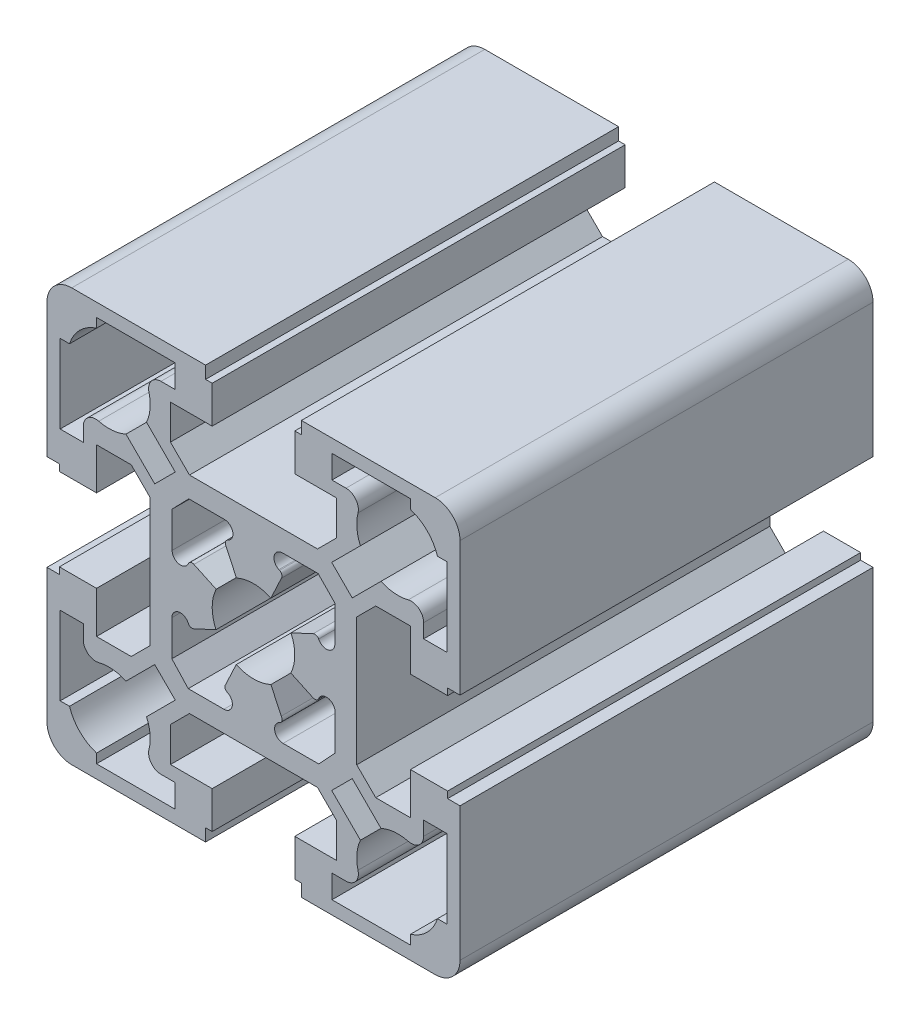
from build123d import *

# Parameters (mm, degrees)
BASE_EXTRUDE_DEPTH = 50


with BuildPart() as part:
    # Sketch1 → Base-Extrude (new body)
    with BuildSketch(Plane.XY):
        with BuildLine():
            Line((7.75, 12.5), (-7.75, 12.5))
            Line((-7.75, 12.5), (-10.05, 14.8))
            Line((-10.05, 14.8), (-10.05, 19))
            Line((-10.05, 19), (-5, 19))
            Line((-5, 19), (-5, 23.5))
            Line((-5, 23.5), (-5.8, 23.5))
            Line((-5.8, 23.5), (-5.8, 25))
            Line((-5.8, 25), (-22, 25))
            ThreePointArc((-22, 25), (-24.121320344, 24.121320344), (-25, 22))
            Line((-25, 22), (-25, 5.8))
            Line((-25, 5.8), (-23.5, 5.8))
            Line((-23.5, 5.8), (-23.5, 5))
            Line((-23.5, 5), (-19, 5))
            Line((-19, 5), (-19, 10.05))
            Line((-19, 10.05), (-14.8, 10.05))
            Line((-14.8, 10.05), (-12.5, 7.75))
            Line((-12.5, 7.75), (-12.5, -7.75))
            Line((-12.5, -7.75), (-14.8, -10.05))
            Line((-14.8, -10.05), (-19, -10.05))
            Line((-19, -10.05), (-19, -5))
            Line((-19, -5), (-23.5, -5))
            Line((-23.5, -5), (-23.5, -5.8))
            Line((-23.5, -5.8), (-25, -5.8))
            Line((-25, -5.8), (-25, -22))
            ThreePointArc((-25, -22), (-24.121320344, -24.121320344), (-22, -25))
            Line((-22, -25), (-5.8, -25))
            Line((-5.8, -25), (-5.8, -23.5))
            Line((-5.8, -23.5), (-5, -23.5))
            Line((-5, -23.5), (-5, -19))
            Line((-5, -19), (-10.05, -19))
            Line((-10.05, -19), (-10.05, -14.8))
            Line((-10.05, -14.8), (-7.75, -12.5))
            Line((-7.75, -12.5), (7.75, -12.5))
            Line((7.75, -12.5), (10.05, -14.8))
            Line((10.05, -14.8), (10.05, -19))
            Line((10.05, -19), (5, -19))
            Line((5, -19), (5, -23.5))
            Line((5, -23.5), (5.8, -23.5))
            Line((5.8, -23.5), (5.8, -25))
            Line((5.8, -25), (22, -25))
            ThreePointArc((22, -25), (24.121320344, -24.121320344), (25, -22))
            Line((25, -22), (25, -5.8))
            Line((25, -5.8), (23.5, -5.8))
            Line((23.5, -5.8), (23.5, -5))
            Line((23.5, -5), (19, -5))
            Line((19, -5), (19, -10.05))
            Line((19, -10.05), (14.8, -10.05))
            Line((14.8, -10.05), (12.5, -7.75))
            Line((12.5, -7.75), (12.5, 7.75))
            Line((12.5, 7.75), (14.8, 10.05))
            Line((14.8, 10.05), (19, 10.05))
            Line((19, 10.05), (19, 5))
            Line((19, 5), (23.5, 5))
            Line((23.5, 5), (23.5, 5.8))
            Line((23.5, 5.8), (25, 5.8))
            Line((25, 5.8), (25, 22))
            ThreePointArc((25, 22), (24.121320344, 24.121320344), (22, 25))
            Line((22, 25), (5.8, 25))
            Line((5.8, 25), (5.8, 23.5))
            Line((5.8, 23.5), (5, 23.5))
            Line((5, 23.5), (5, 19))
            Line((5, 19), (10.05, 19))
            Line((10.05, 19), (10.05, 14.8))
            Line((10.05, 14.8), (7.75, 12.5))
        make_face()
        with BuildLine():
            Line((3.505344903, 9.96577797), (7.822665473, 9.96577797))
            Line((7.822665473, 9.96577797), (9.85958722, 7.877775505))
            Line((9.85958722, 7.877775505), (9.850440617, 3.560464625))
            ThreePointArc((9.850440617, 3.560464625), (9.041479714, 2.556883244), (7.886596034, 3.129453777))
            Line((7.886596034, 3.129453777), (7.895357337, 3.110560702))
            ThreePointArc((7.895357337, 3.110560702), (7.613761881, 3.369695047), (7.231408173, 3.353812643))
            Line((7.231408173, 3.353812643), (4.535858613, 2.103802901))
            ThreePointArc((4.535858613, 2.103802901), (4.999987062, -0.011374477), (4.526239826, -2.124418281))
            Line((4.526239826, -2.124418281), (7.221789386, -3.374428023))
            ThreePointArc((7.221789386, -3.374428023), (7.604143095, -3.390310427), (7.885738551, -3.131176083))
            Line((7.885738551, -3.131176083), (7.907030563, -3.085261502))
            ThreePointArc((7.907030563, -3.085261502), (9.06210775, -2.511832674), (9.873011121, -3.514558784))
            Line((9.873011121, -3.514558784), (9.891304287, -7.831840598))
            Line((9.891304287, -7.831840598), (7.902556996, -9.96577797))
            Line((7.902556996, -9.96577797), (3.585236427, -9.96577797))
            ThreePointArc((3.585236427, -9.96577797), (2.578793519, -9.158022138), (3.149568198, -8.000605586))
            Line((3.149568198, -8.000605586), (3.18152755, -7.985702696))
            ThreePointArc((3.18152755, -7.985702696), (3.456201605, -7.650108756), (3.365281923, -7.226077224))
            Line((3.365281923, -7.226077224), (2.109564241, -4.533181964))
            ThreePointArc((2.109564241, -4.533181964), (0.010417022, -4.999989149), (-2.090657066, -4.541932742))
            Line((-2.090657066, -4.541932742), (-3.352077054, -7.232161617))
            ThreePointArc((-3.352077054, -7.232161617), (-3.44721565, -7.657355486), (-3.172730689, -7.995732769))
            Line((-3.172730689, -7.995732769), (-3.144425204, -8.009004913))
            ThreePointArc((-3.144425204, -8.009004913), (-2.57802929, -9.162157696), (-3.580406528, -9.96577797))
            Line((-3.580406528, -9.96577797), (-7.897727097, -9.96577797))
            Line((-7.897727097, -9.96577797), (-9.879549599, -7.825407892))
            Line((-9.879549599, -7.825407892), (-9.870402996, -3.508097012))
            ThreePointArc((-9.870402996, -3.508097012), (-9.064593686, -2.507341079), (-7.912547347, -3.076226227))
            Line((-7.912547347, -3.076226227), (-7.892788633, -3.118598925))
            ThreePointArc((-7.892788633, -3.118598925), (-7.610644812, -3.377136104), (-7.228325609, -3.360443688))
            Line((-7.228325609, -3.360443688), (-4.535430348, -2.104726005))
            ThreePointArc((-4.535430348, -2.104726005), (-4.999945915, 0.0232561), (-4.515655235, 2.146825051))
            Line((-4.515655235, 2.146825051), (-7.208550496, 3.402542734))
            ThreePointArc((-7.208550496, 3.402542734), (-7.590869698, 3.419235151), (-7.87301352, 3.160697971))
            Line((-7.87301352, 3.160697971), (-7.892726665, 3.118422996))
            ThreePointArc((-7.892726665, 3.118422996), (-9.044676902, 2.549585303), (-9.850418992, 3.550257755))
            Line((-9.850418992, 3.550257755), (-9.859565596, 7.867568635))
            Line((-9.859565596, 7.867568635), (-7.833159396, 9.96577797))
            Line((-7.833159396, 9.96577797), (-3.515838827, 9.96577797))
            ThreePointArc((-3.515838827, 9.96577797), (-2.513461589, 9.162157696), (-3.079857503, 8.009004913))
            Line((-3.079857503, 8.009004913), (-3.127507547, 7.986662309))
            ThreePointArc((-3.127507547, 7.986662309), (-3.398642875, 7.661708995), (-3.32345011, 7.245229618))
            Line((-3.32345011, 7.245229618), (-2.062030122, 4.555000744))
            ThreePointArc((-2.062030122, 4.555000744), (0.02615125, 4.999931611), (2.109564241, 4.533181964))
            Line((2.109564241, 4.533181964), (3.365281923, 7.226077224))
            ThreePointArc((3.365281923, 7.226077224), (3.436001626, 7.641565147), (3.163996416, 7.963504048))
            Line((3.163996416, 7.963504048), (3.072985785, 8.005708494))
            ThreePointArc((3.072985785, 8.005708494), (2.501750519, 9.159434003), (3.505344903, 9.96577797))
        make_face(mode=Mode.SUBTRACT)
        with BuildLine():
            Line((-23.4, -19), (-23.4, -9.5))
            Line((-23.4, -9.5), (-20.6, -9.5))
            Line((-20.6, -9.5), (-20.6, -11.199838588))
            ThreePointArc((-20.6, -11.199838588), (-20.020914539, -12.383864099), (-18.730778117, -12.653686998))
            ThreePointArc((-18.730778117, -12.653686998), (-17.057404686, -12.519470523), (-15.433920888, -12.946662588))
            Line((-15.433920888, -12.946662588), (-11.955404051, -9.46814575))
            Line((-11.955404051, -9.46814575), (-9.468145751, -11.955404051))
            Line((-9.468145751, -11.955404051), (-12.946662588, -15.433920888))
            ThreePointArc((-12.946662588, -15.433920888), (-12.519470523, -17.057404686), (-12.653686998, -18.730778117))
            ThreePointArc((-12.653686998, -18.730778117), (-12.383864099, -20.020914539), (-11.199838588, -20.6))
            Line((-11.199838588, -20.6), (-9.5, -20.6))
            Line((-9.5, -20.6), (-9.5, -23.4))
            Line((-9.5, -23.4), (-19, -23.4))
            Line((-19, -23.4), (-19, -22.269696007))
            ThreePointArc((-19, -22.269696007), (-21.035533906, -21.035533906), (-22.269696007, -19))
            Line((-22.269696007, -19), (-23.4, -19))
        make_face(mode=Mode.SUBTRACT)
        with BuildLine():
            Line((-23.4, 9.5), (-23.4, 19))
            Line((-23.4, 19), (-22.269696007, 19))
            ThreePointArc((-22.269696007, 19), (-21.035533906, 21.035533906), (-19, 22.269696007))
            Line((-19, 22.269696007), (-19, 23.4))
            Line((-19, 23.4), (-9.5, 23.4))
            Line((-9.5, 23.4), (-9.5, 20.6))
            Line((-9.5, 20.6), (-11.199838588, 20.6))
            ThreePointArc((-11.199838588, 20.6), (-12.383864099, 20.020914539), (-12.653686998, 18.730778117))
            ThreePointArc((-12.653686998, 18.730778117), (-12.519470523, 17.057404686), (-12.946662588, 15.433920888))
            Line((-12.946662588, 15.433920888), (-9.468145751, 11.955404051))
            Line((-9.468145751, 11.955404051), (-11.955404051, 9.46814575))
            Line((-11.955404051, 9.46814575), (-15.433920888, 12.946662588))
            ThreePointArc((-15.433920888, 12.946662588), (-17.057404686, 12.519470523), (-18.730778117, 12.653686998))
            ThreePointArc((-18.730778117, 12.653686998), (-20.020914539, 12.383864099), (-20.6, 11.199838588))
            Line((-20.6, 11.199838588), (-20.6, 9.5))
            Line((-20.6, 9.5), (-23.4, 9.5))
        make_face(mode=Mode.SUBTRACT)
        with BuildLine():
            Line((23.4, -9.5), (23.4, -19))
            Line((23.4, -19), (22.269696007, -19))
            ThreePointArc((22.269696007, -19), (21.035533906, -21.035533906), (19, -22.269696007))
            Line((19, -22.269696007), (19, -23.4))
            Line((19, -23.4), (9.5, -23.4))
            Line((9.5, -23.4), (9.5, -20.6))
            Line((9.5, -20.6), (11.199838588, -20.6))
            ThreePointArc((11.199838588, -20.6), (12.383864099, -20.020914539), (12.653686998, -18.730778117))
            ThreePointArc((12.653686998, -18.730778117), (12.519470523, -17.057404686), (12.946662588, -15.433920888))
            Line((12.946662588, -15.433920888), (9.468145751, -11.955404051))
            Line((9.468145751, -11.955404051), (11.955404051, -9.46814575))
            Line((11.955404051, -9.46814575), (15.433920888, -12.946662588))
            ThreePointArc((15.433920888, -12.946662588), (17.057404686, -12.519470523), (18.730778117, -12.653686998))
            ThreePointArc((18.730778117, -12.653686998), (20.020914539, -12.383864099), (20.6, -11.199838588))
            Line((20.6, -11.199838588), (20.6, -9.5))
            Line((20.6, -9.5), (23.4, -9.5))
        make_face(mode=Mode.SUBTRACT)
        with BuildLine():
            Line((23.4, 19), (23.4, 9.5))
            Line((23.4, 9.5), (20.6, 9.5))
            Line((20.6, 9.5), (20.6, 11.199838588))
            ThreePointArc((20.6, 11.199838588), (20.020914539, 12.383864099), (18.730778117, 12.653686998))
            ThreePointArc((18.730778117, 12.653686998), (17.057404686, 12.519470523), (15.433920888, 12.946662588))
            Line((15.433920888, 12.946662588), (11.955404051, 9.46814575))
            Line((11.955404051, 9.46814575), (9.46814575, 11.955404051))
            Line((9.46814575, 11.955404051), (12.946662588, 15.433920888))
            ThreePointArc((12.946662588, 15.433920888), (12.519470523, 17.057404686), (12.653686998, 18.730778117))
            ThreePointArc((12.653686998, 18.730778117), (12.383864099, 20.020914539), (11.199838588, 20.6))
            Line((11.199838588, 20.6), (9.5, 20.6))
            Line((9.5, 20.6), (9.5, 23.4))
            Line((9.5, 23.4), (19, 23.4))
            Line((19, 23.4), (19, 22.269696007))
            ThreePointArc((19, 22.269696007), (21.035533906, 21.035533906), (22.269696007, 19))
            Line((22.269696007, 19), (23.4, 19))
        make_face(mode=Mode.SUBTRACT)
    extrude(amount=-BASE_EXTRUDE_DEPTH)


solid = part.part
